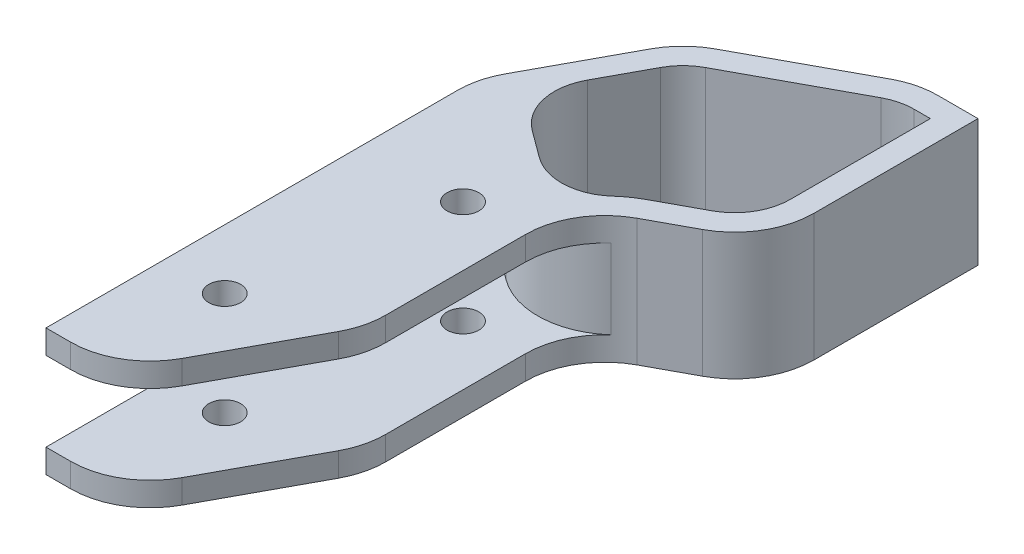
from build123d import *

# Parameters (mm, degrees)
SKETCH1_R           = 2
BOSS_EXTRUDE1_DEPTH = 3
FILLET1_R           = 10
BOSS_EXTRUDE2_DEPTH = 10
BOSS_EXTRUDE3_START = 10
SKETCH2_3_R         = 2
BOSS_EXTRUDE3_DEPTH = 3
CUT_EXTRUDE1_DEPTH  = 74.447466489


with BuildPart() as part:
    # Sketch1 → Boss-Extrude1 (new body)
    with BuildSketch(Plane(origin=(0, 0, 0), x_dir=(1, 0, 0), z_dir=(0, 1, 0))):
        Polygon((1.560538705, -15), (12.5, 5.232110419), (12.5, 31.328870119), (28.35, 39.898933149), (28.35, 66.496675358), (20.756215513, 66.496675358), (1.560538705, 56.117611626), (-7.5, 39.360495841), (-7.5, -15), align=None)
        with Locations(Location((0, 0, 0), (0, 0, 270))):
            Circle(SKETCH1_R, mode=Mode.SUBTRACT)
        with Locations(Location((5, 25, 0), (0, 0, 270))):
            Circle(SKETCH1_R, mode=Mode.SUBTRACT)
    extrude(amount=BOSS_EXTRUDE1_DEPTH)

    # Fillet1
    fillet1_edges = [part.edges().sort_by_distance(p)[0] for p in [
        (-7.5, 1.5, -39.360495841),
        (1.560538705, 1.5, -56.117611626),
        (20.756215513, 1.5, -66.496675358),
        (28.35, 1.5, -39.898933149),
        (12.5, 1.5, -31.328870119),
        (12.5, 1.5, -5.232110419),
        (1.560538705, 1.5, 15),
    ]]
    fillet(fillet1_edges, radius=FILLET1_R)

    # Sketch2 → Boss-Extrude2 (add)
    with BuildSketch(Plane(origin=(0, 3, 0), x_dir=(1, 0, 0), z_dir=(0, 1, 0))):
        with BuildLine():
            Line((-0.212131961, 34.733789396), (3.216589734, 32.20755665))
            ThreePointArc((3.216589734, 32.20755665), (9.62795757, 30.269843196), (15.824142619, 32.813003004))
            ThreePointArc((15.824142619, 32.813003004), (16.744165524, 33.545104209), (17.743757909, 34.164159444))
            Line((17.743757909, 34.164159444), (23.106242091, 37.063643824))
            ThreePointArc((23.106242091, 37.063643824), (26.939598969, 40.739700904), (28.35, 45.860129553))
            Line((28.35, 45.860129553), (28.35, 66.496675358))
            Line((28.35, 66.496675358), (23.286604522, 66.496675358))
            ThreePointArc((23.286604522, 66.496675358), (20.833530664, 66.191128856), (18.530362432, 65.293161086))
            Line((18.530362432, 65.293161086), (4.182884994, 57.535508975))
            ThreePointArc((4.182884994, 57.535508975), (1.868059273, 55.810091058), (0.142641356, 53.495265337))
            Line((0.142641356, 53.495265337), (-3.076922186, 47.54080713))
            ThreePointArc((-3.076922186, 47.54080713), (-4.039266122, 40.601621249), (-0.212131961, 34.733789396))
        make_face()
        with BuildLine():
            Line((1.56737669, 37.149022089), (4.996098385, 34.622789343))
            ThreePointArc((4.996098385, 34.622789343), (9.48405587, 33.266389925), (13.821385404, 35.046601791))
            ThreePointArc((13.821385404, 35.046601791), (15.017415181, 35.998333357), (16.316885282, 36.803105162))
            Line((16.316885282, 36.803105162), (21.679369463, 39.702589543))
            ThreePointArc((21.679369463, 39.702589543), (24.362719279, 42.275829499), (25.35, 45.860129553))
            Line((25.35, 45.860129553), (25.35, 63.496675358))
            Line((25.35, 63.496675358), (23.286604522, 63.496675358))
            ThreePointArc((23.286604522, 63.496675358), (21.569452821, 63.282792807), (19.957235059, 62.654215368))
            Line((19.957235059, 62.654215368), (5.609757621, 54.896563256))
            ThreePointArc((5.609757621, 54.896563256), (3.989379616, 53.688770715), (2.781587075, 52.06839271))
            Line((2.781587075, 52.06839271), (-0.437976468, 46.113934502))
            ThreePointArc((-0.437976468, 46.113934502), (-1.111617222, 41.256504386), (1.56737669, 37.149022089))
        make_face(mode=Mode.SUBTRACT)
    extrude(amount=BOSS_EXTRUDE2_DEPTH)

    # Sketch2_3 → Boss-Extrude3 (add)
    with BuildSketch(Plane(origin=(0, 3, 0), x_dir=(1, 0, 0), z_dir=(0, 1, 0)).offset(BOSS_EXTRUDE3_START)):
        with BuildLine():
            ThreePointArc((-3.076922186, 47.54080713), (-4.039266122, 40.601621249), (-0.212131961, 34.733789396))
            Line((-0.212131961, 34.733789396), (3.216589734, 32.20755665))
            ThreePointArc((3.216589734, 32.20755665), (9.62795757, 30.269843196), (15.824142619, 32.813003004))
            ThreePointArc((15.824142619, 32.813003004), (16.744165524, 33.545104209), (17.743757909, 34.164159444))
            Line((17.743757909, 34.164159444), (23.106242091, 37.063643824))
            ThreePointArc((23.106242091, 37.063643824), (26.939598969, 40.739700904), (28.35, 45.860129553))
            Line((28.35, 45.860129553), (28.35, 66.496675358))
            Line((28.35, 66.496675358), (23.286604522, 66.496675358))
            ThreePointArc((23.286604522, 66.496675358), (20.833530664, 66.191128856), (18.530362432, 65.293161086))
            Line((18.530362432, 65.293161086), (4.182884994, 57.535508975))
            ThreePointArc((4.182884994, 57.535508975), (1.868059273, 55.810091058), (0.142641356, 53.495265337))
            Line((0.142641356, 53.495265337), (-3.076922186, 47.54080713))
        make_face()
        with BuildLine():
            Line((4.996098385, 34.622789343), (1.56737669, 37.149022089))
            ThreePointArc((1.56737669, 37.149022089), (-1.111617222, 41.256504386), (-0.437976468, 46.113934502))
            Line((-0.437976468, 46.113934502), (2.781587075, 52.06839271))
            ThreePointArc((2.781587075, 52.06839271), (3.989379616, 53.688770715), (5.609757621, 54.896563256))
            Line((5.609757621, 54.896563256), (19.957235059, 62.654215368))
            ThreePointArc((19.957235059, 62.654215368), (21.569452821, 63.282792807), (23.286604522, 63.496675358))
            Line((23.286604522, 63.496675358), (25.35, 63.496675358))
            Line((25.35, 63.496675358), (25.35, 45.860129553))
            ThreePointArc((25.35, 45.860129553), (24.362719279, 42.275829499), (21.679369463, 39.702589543))
            Line((21.679369463, 39.702589543), (16.316885282, 36.803105162))
            ThreePointArc((16.316885282, 36.803105162), (15.017415181, 35.998333357), (13.821385404, 35.046601791))
            ThreePointArc((13.821385404, 35.046601791), (9.48405587, 33.266389925), (4.996098385, 34.622789343))
        make_face(mode=Mode.SUBTRACT)
        with BuildLine():
            Line((3.216589734, 32.20755665), (-0.212131961, 34.733789396))
            ThreePointArc((-0.212131961, 34.733789396), (-4.039266122, 40.601621249), (-3.076922186, 47.54080713))
            Line((-3.076922186, 47.54080713), (-6.296485729, 41.586348922))
            ThreePointArc((-6.296485729, 41.586348922), (-7.194453499, 39.28318069), (-7.5, 36.830106832))
            Line((-7.5, 36.830106832), (-7.5, -15))
            Line((-7.5, -15), (-4.400657699, -15))
            ThreePointArc((-4.400657699, -15), (0.71977095, -13.589598969), (4.39582803, -9.756242091))
            Line((4.39582803, -9.756242091), (11.296485729, 3.006257338))
            ThreePointArc((11.296485729, 3.006257338), (12.194453499, 5.30942557), (12.5, 7.762499429))
            Line((12.5, 7.762499429), (12.5, 25.367673715))
            ThreePointArc((12.5, 25.367673715), (13.368774074, 29.444524594), (15.824142619, 32.813003004))
            ThreePointArc((15.824142619, 32.813003004), (9.62795757, 30.269843196), (3.216589734, 32.20755665))
        make_face()
        with Locations(Location((0, 0, 0), (0, 0, 270))):
            Circle(SKETCH2_3_R, mode=Mode.SUBTRACT)
        with Locations(Location((5, 25, 0), (0, 0, 270))):
            Circle(SKETCH2_3_R, mode=Mode.SUBTRACT)
    extrude(amount=BOSS_EXTRUDE3_DEPTH)

    # Sketch4 → Cut-Extrude1 (cut, through all)
    with BuildSketch(Plane(origin=(0, 3, 0), x_dir=(1, 0, 0), z_dir=(0, 1, 0))):
        with BuildLine():
            Line((19.957235059, 62.654215368), (5.609757621, 54.896563256))
            ThreePointArc((5.609757621, 54.896563256), (3.989379616, 53.688770715), (2.781587075, 52.06839271))
            Line((2.781587075, 52.06839271), (-0.437976468, 46.113934502))
            ThreePointArc((-0.437976468, 46.113934502), (-1.111617222, 41.256504386), (1.56737669, 37.149022089))
            Line((1.56737669, 37.149022089), (4.996098385, 34.622789343))
            ThreePointArc((4.996098385, 34.622789343), (9.48405587, 33.266389925), (13.821385404, 35.046601791))
            ThreePointArc((13.821385404, 35.046601791), (15.017415181, 35.998333357), (16.316885282, 36.803105162))
            Line((16.316885282, 36.803105162), (21.679369463, 39.702589543))
            ThreePointArc((21.679369463, 39.702589543), (24.362719279, 42.275829499), (25.35, 45.860129553))
            Line((25.35, 45.860129553), (25.35, 63.496675358))
            Line((25.35, 63.496675358), (23.286604522, 63.496675358))
            ThreePointArc((23.286604522, 63.496675358), (21.569452821, 63.282792807), (19.957235059, 62.654215368))
        make_face()
    extrude(amount=-CUT_EXTRUDE1_DEPTH, mode=Mode.SUBTRACT)


solid = part.part
